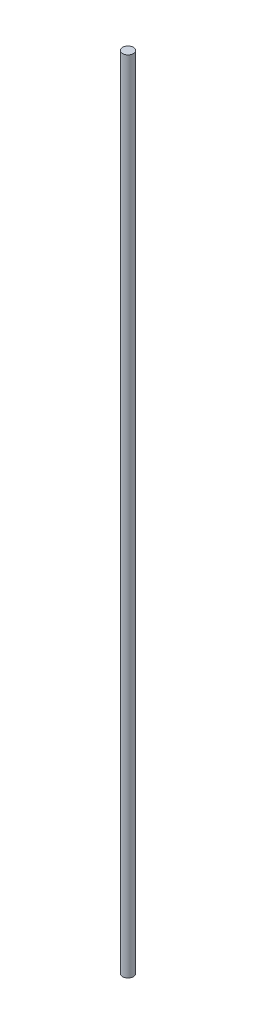
from build123d import *

# Parameters (mm, degrees)
SKETCH1_R           = 1
BOSS_EXTRUDE1_DEPTH = 146.05


with BuildPart() as part:
    # Sketch1 → Boss-Extrude1 (new body)
    with BuildSketch(Plane(origin=(0, 0, 0), x_dir=(1, 0, 0), z_dir=(0, 1, 0))):
        Circle(SKETCH1_R)
    extrude(amount=BOSS_EXTRUDE1_DEPTH)


solid = part.part
